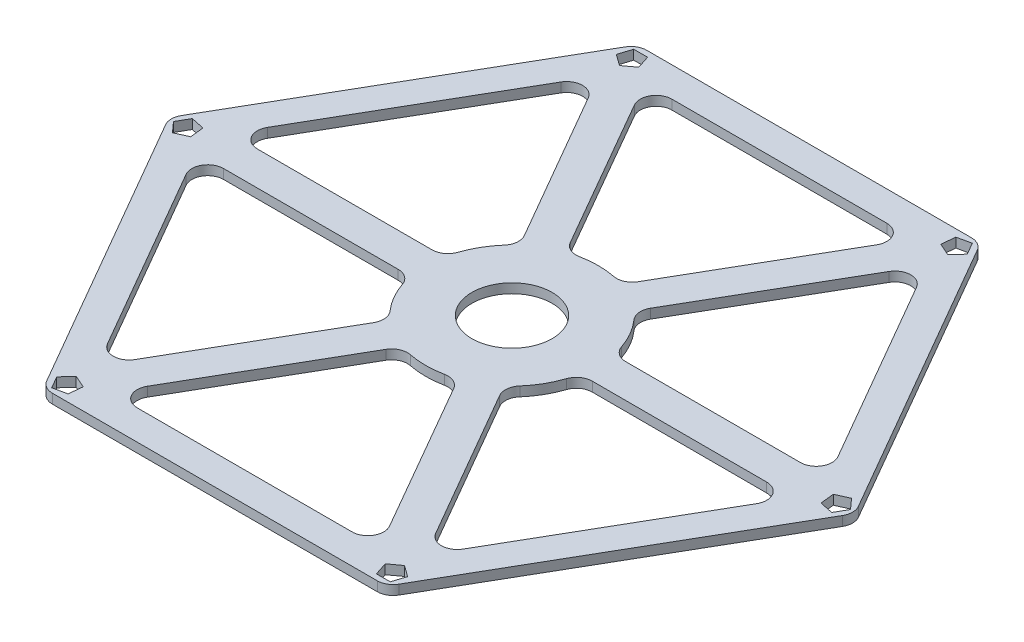
from build123d import *

# Parameters (mm, degrees)
BOSS_EXTRUDE1_DEPTH = 1.8
FILLET1_R           = 3
FILLET2_R           = 3
SKETCH3_R           = 7.6
CUT_EXTRUDE1_DEPTH  = 10
SCALE1_SCALE        = 1.15


with BuildPart() as part:
    # Sketch1 → Boss-Extrude1 (new body)
    with BuildSketch(Plane(origin=(0, 0, 0), x_dir=(1, 0, 0), z_dir=(0, 1, 0))):
        Polygon((-32.5, 56.291651246), (-65, 0), (-32.5, -56.291651246), (32.5, -56.291651246), (65, 0), (32.5, 56.291651246), align=None)
        with BuildLine():
            Line((-31.098446917, 47.455472674), (-56.646868343, 3.204308711))
            Line((-56.646868343, 3.204308711), (-16.055097208, 3.204308711))
            ThreePointArc((-16.055097208, 3.204308711), (-14.178339307, 8.185868015), (-10.802561349, 12.301967686))
            Line((-10.802561349, 12.301967686), (-31.098446917, 47.455472674))
        make_face(mode=Mode.SUBTRACT)
        with BuildLine():
            Line((-56.646868343, -3.204308711), (-31.098446917, -47.455472674))
            Line((-31.098446917, -47.455472674), (-10.802561349, -12.301967686))
            ThreePointArc((-10.802561349, -12.301967686), (-14.178339307, -8.185868015), (-16.055097208, -3.204308711))
            Line((-16.055097208, -3.204308711), (-56.646868343, -3.204308711))
        make_face(mode=Mode.SUBTRACT)
        with BuildLine():
            Line((-25.548421426, -50.659781385), (3, -50.659781385))
            Line((3, -50.659781385), (25.548291416, -50.659781385))
            Line((25.548291416, -50.659781385), (5.29797501, -15.490810226))
            ThreePointArc((5.29797501, -15.490810226), (4.194244938, -15.825360977), (3.069700506, -16.08137679))
            ThreePointArc((3.069700506, -16.08137679), (-1.128661889, -16.332784913), (-5.252535858, -15.506276397))
            Line((-5.252535858, -15.506276397), (-25.548421426, -50.659781385))
        make_face(mode=Mode.SUBTRACT)
        with BuildLine():
            Line((31.098446917, -47.455472674), (56.646803338, -3.204421303))
            Line((56.646803338, -3.204421303), (16.064422686, -3.157224166))
            ThreePointArc((16.064422686, -3.157224166), (14.190323862, -8.165074976), (10.802561349, -12.301967686))
            Line((10.802561349, -12.301967686), (31.098446917, -47.455472674))
        make_face(mode=Mode.SUBTRACT)
        with BuildLine():
            Line((56.646868343, 3.204308711), (31.098511922, 47.455360082))
            Line((31.098511922, 47.455360082), (10.766447676, 12.33358606))
            ThreePointArc((10.766447676, 12.33358606), (14.166324284, 8.206643464), (16.055097208, 3.204308711))
            Line((16.055097208, 3.204308711), (56.646868343, 3.204308711))
        make_face(mode=Mode.SUBTRACT)
        with BuildLine():
            Line((25.548421426, 50.659781385), (-25.548291416, 50.659781385))
            Line((-25.548291416, 50.659781385), (-5.29797501, 15.490810226))
            ThreePointArc((-5.29797501, 15.490810226), (-0.023999578, 16.37171844), (5.252535858, 15.506276397))
            Line((5.252535858, 15.506276397), (25.548421426, 50.659781385))
        make_face(mode=Mode.SUBTRACT)
        Polygon((28.926541222, 52.315471461), (31.319181202, 51.258876955), (33.063428707, 53.207907141), (31.748792971, 55.469068546), (29.192055897, 54.917512964), align=None, mode=Mode.SUBTRACT)
        Polygon((-30.843256685, 51.208855273), (-28.731899012, 52.752645025), (-29.547684912, 55.237722767), (-32.163226, 55.229795525), (-32.963933391, 52.739818478), align=None, mode=Mode.SUBTRACT)
        Polygon((59.769797908, 1.106616188), (60.051080214, -1.493768069), (62.61111362, -2.029815626), (63.912018971, 0.239273021), (62.155989288, 2.177694486), align=None, mode=Mode.SUBTRACT)
        Polygon((30.843256685, -51.208855273), (28.731899012, -52.752645025), (29.547684912, -55.237722767), (32.163226, -55.229795525), (32.963933391, -52.739818478), align=None, mode=Mode.SUBTRACT)
        Polygon((-28.926541222, -52.315471461), (-31.319181202, -51.258876955), (-33.063428707, -53.207907141), (-31.748792971, -55.469068546), (-29.192055897, -54.917512964), align=None, mode=Mode.SUBTRACT)
        Polygon((-59.769797908, -1.106616188), (-60.051080214, 1.493768069), (-62.61111362, 2.029815626), (-63.912018971, -0.239273021), (-62.155989288, -2.177694486), align=None, mode=Mode.SUBTRACT)
    extrude(amount=BOSS_EXTRUDE1_DEPTH)

    # Fillet1
    fillet1_edges = [part.edges().sort_by_distance(p)[0] for p in [
        (32.5, 0.9, -56.291651246),
        (65, 0.9, 0),
        (32.5, 0.9, 56.291651246),
        (-32.5, 0.9, 56.291651246),
        (-65, 0.9, 0),
        (-32.5, 0.9, -56.291651246),
    ]]
    fillet(fillet1_edges, radius=FILLET1_R)

    # Fillet2
    fillet2_edges = [part.edges().sort_by_distance(p)[0] for p in [
        (5.29797501, 0.9, 15.490810226),
        (-5.252535858, 0.9, 15.506276397),
        (-25.548421426, 0.9, 50.659781385),
        (25.548291416, 0.9, 50.659781385),
        (-25.548291416, 0.9, -50.659781385),
        (-5.29797501, 0.9, -15.490810226),
        (5.252535858, 0.9, -15.506276397),
        (25.548421426, 0.9, -50.659781385),
        (31.098511922, 0.9, -47.455360082),
        (10.766447676, 0.9, -12.33358606),
        (16.055097208, 0.9, -3.204308711),
        (56.646868343, 0.9, -3.204308711),
        (56.646803338, 0.9, 3.204421303),
        (16.064422686, 0.9, 3.157224166),
        (10.802561349, 0.9, 12.301967686),
        (31.098446917, 0.9, 47.455472674),
        (-31.098446917, 0.9, 47.455472674),
        (-10.802561349, 0.9, 12.301967686),
        (-16.055097208, 0.9, 3.204308711),
        (-56.646868343, 0.9, 3.204308711),
        (-10.802561349, 0.9, -12.301967686),
        (-31.098446917, 0.9, -47.455472674),
        (-56.646868343, 0.9, -3.204308711),
        (-16.055097208, 0.9, -3.204308711),
    ]]
    fillet(fillet2_edges, radius=FILLET2_R)

    # Sketch3 → Cut-Extrude1 (cut)
    with BuildSketch(Plane(origin=(0, 3.6, 0), x_dir=(1, 0, 0), z_dir=(0, 1, 0))):
        Circle(SKETCH3_R)
    extrude(amount=-CUT_EXTRUDE1_DEPTH, mode=Mode.SUBTRACT)


with BuildPart() as part_1:
    # Scale1: scaled about (-0.010587945, 0.9, 0.004669606)
    add(part.part.scale(SCALE1_SCALE).moved(Location((0.001588192, -0.135, -0.000700441))))


solid = part_1.part
